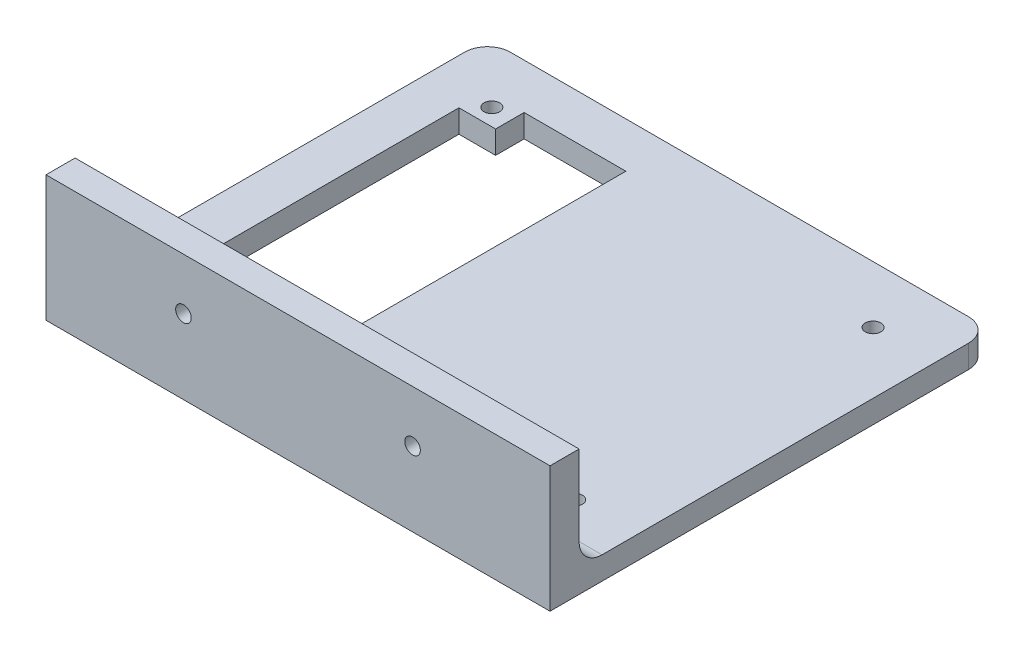
from build123d import *

# Parameters (mm, degrees)
SKETCH1_W                      = 110
SKETCH1_H                      = 90
BOSS_EXTRUDE1_DEPTH            = 2.5
M3_CLEARANCE_HOLE1_D           = 3.4
M3_CLEARANCE_HOLE1_DEPTH       = 5
SKETCH5_W                      = 110
SKETCH5_H                      = 6.35
BOSS_EXTRUDE2_DEPTH            = 25
BOSS_EXTRUDE2_DEPTH_BACK       = 2.5
CBORE_FOR_M3_SHCS1_D           = 3.4
CBORE_FOR_M3_SHCS1_DEPTH       = 6.35
CBORE_FOR_M3_SHCS1_CBORE_D     = 6.5
CBORE_FOR_M3_SHCS1_CBORE_DEPTH = 3
CUT_EXTRUDE1_DEPTH             = 6
BOSS_EXTRUDE4_DEPTH            = 5
FILLET1_R                      = 5
FILLET2_R                      = 5


with BuildPart() as part:
    # Sketch1 → Boss-Extrude1 (new body, symmetric)
    with BuildSketch(Plane(origin=(0, 0, 0), x_dir=(1, 0, 0), z_dir=(0, 1, 0))):
        with Locations((55, -45)):
            Rectangle(SKETCH1_W, SKETCH1_H)
    extrude(amount=BOSS_EXTRUDE1_DEPTH, both=True)

    # M3 Clearance Hole1
    with Locations(Plane(origin=(0, 2.5, 0), x_dir=(1, 0, 0), z_dir=(0, 1, 0))):
        with Locations((13.4, -77.55755), (96.6, -12.44245), (96.6, -77.55755), (13.4, -12.44245)):
            Hole(M3_CLEARANCE_HOLE1_D / 2, depth=M3_CLEARANCE_HOLE1_DEPTH)

    # Sketch5 → Boss-Extrude2 (add, two sides)
    with BuildSketch(Plane(origin=(0, 0, 0), x_dir=(1, 0, 0), z_dir=(0, 1, 0))) as boss_extrude2_sk:
        with Locations((55, -93.175)):
            Rectangle(SKETCH5_W, SKETCH5_H)
    extrude(amount=BOSS_EXTRUDE2_DEPTH)
    extrude(boss_extrude2_sk.sketch, amount=-BOSS_EXTRUDE2_DEPTH_BACK)

    # CBORE for M3 SHCS1
    with Locations(Plane(origin=(0, 0, 90), x_dir=(-1, 0, 0), z_dir=(0, 0, -1))):
        with Locations((-80, 13.75), (-30, 13.75)):
            CounterBoreHole(CBORE_FOR_M3_SHCS1_D / 2, CBORE_FOR_M3_SHCS1_CBORE_D / 2, CBORE_FOR_M3_SHCS1_CBORE_DEPTH, depth=CBORE_FOR_M3_SHCS1_DEPTH)

    # Sketch8 → Cut-Extrude1 (cut, through all)
    with BuildSketch(Plane(origin=(0, 2.5, 0), x_dir=(1, 0, 0), z_dir=(0, 1, 0))):
        Polygon((17.9, -9.9), (92.1, -9.9), (92.1, -16.12616408), (100.1, -16.12616408), (100.1, -73.87383592), (92.1, -73.87383592), (92.1, -80.1), (17.9, -80.1), (17.9, -73.87383592), (9.9, -73.87383592), (9.9, -16.12616408), (17.9, -16.12616408), align=None)
    extrude(amount=-CUT_EXTRUDE1_DEPTH, mode=Mode.SUBTRACT)

    # Sketch10 → Boss-Extrude4 (add, through all)
    with BuildSketch(Plane(origin=(0, 2.5, 0), x_dir=(1, 0, 0), z_dir=(0, 1, 0))):
        Polygon((40.1, -9.9), (92.1, -9.9), (92.1, -16.12616408), (100.1, -16.12616408), (100.1, -73.87383592), (92.1, -73.87383592), (92.1, -80.1), (40.1, -80.1), align=None)
    extrude(amount=-BOSS_EXTRUDE4_DEPTH)

    # Fillet1
    fillet1_edges = [part.edges().sort_by_distance(p)[0] for p in [
        (0, 0, 0),
        (110, 0, 0),
    ]]
    fillet(fillet1_edges, radius=FILLET1_R)

    # Fillet2
    fillet2_edges = [part.edges().sort_by_distance(p)[0] for p in [
        (55, 2.5, 90),
    ]]
    fillet(fillet2_edges, radius=FILLET2_R)


solid = part.part
